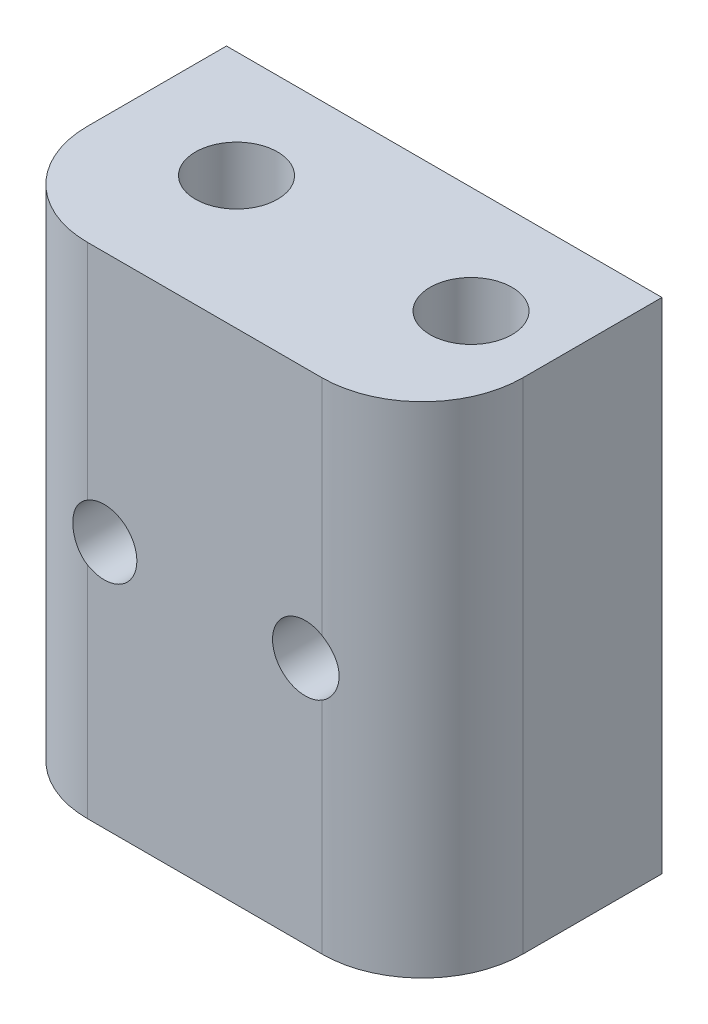
from build123d import *

# Parameters (mm, degrees)
SKETCH1_W          = 26
SKETCH1_H          = 29.8
EXTRUDE1_DEPTH     = 14.3
FILLET1_R          = 6
SKETCH3_R          = 2.45
CUT_EXTRUDE1_DEPTH = 30.8
SKETCH2_R          = 1.95
EXTRUDE2_DEPTH     = 15.3


with BuildPart() as part:
    # Sketch1 → Extrude1 (new body)
    with BuildSketch(Plane.XY):
        with Locations((-0.145304935, -1.279569379)):
            Rectangle(SKETCH1_W, SKETCH1_H)
    extrude(amount=EXTRUDE1_DEPTH)

    # Fillet1
    fillet1_edges = [part.edges().sort_by_distance(p)[0] for p in [
        (12.854695065, -1.279569379, 14.3),
        (-13.145304935, -1.279569379, 14.3),
    ]]
    fillet(fillet1_edges, radius=FILLET1_R)

    # Sketch3 → Cut-Extrude1 (cut, through all)
    with BuildSketch(Plane(origin=(0, 13.620430621, 0), x_dir=(-1, 0, 0), z_dir=(0, 1, 0))):
        with Locations((-7.854695065, 6.4000002)):
            Circle(SKETCH3_R)
        with Locations((6.145304935, 6.4)):
            Circle(SKETCH3_R)
    extrude(amount=-CUT_EXTRUDE1_DEPTH, mode=Mode.SUBTRACT)

    # Sketch2 → Extrude2 (cut, through all)
    with BuildSketch(Plane.XY.offset(14.3)):
        with Locations((-6.145304935, -1.379569379)):
            Circle(SKETCH2_R)
        with Locations((5.854695065, -1.379569379)):
            Circle(SKETCH2_R)
    extrude(amount=-EXTRUDE2_DEPTH, mode=Mode.SUBTRACT)


solid = part.part
